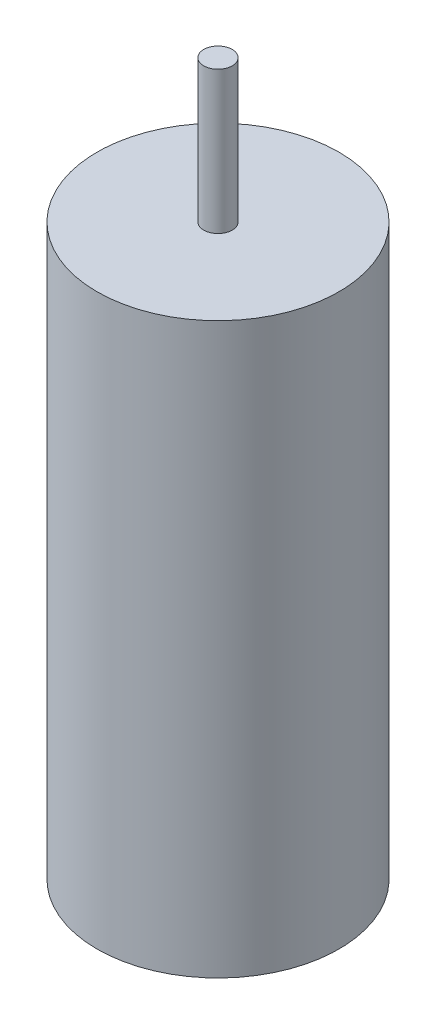
from build123d import *

# Parameters (mm, degrees)
SKETCH_1_R      = 4.25
EXTRUDE_1_DEPTH = 20
SKETCH_2_R      = 0.5
EXTRUDE_2_DEPTH = 5


with BuildPart() as part:
    # 草图1 → 凸台-拉伸1 (new body)
    with BuildSketch(Plane(origin=(0, 0, 0), x_dir=(1, 0, 0), z_dir=(0, 1, 0))):
        Circle(SKETCH_1_R)
    extrude(amount=EXTRUDE_1_DEPTH)

    # 草图2 → 凸台-拉伸2 (add)
    with BuildSketch(Plane(origin=(0, 20, 0), x_dir=(1, 0, 0), z_dir=(0, 1, 0))):
        Circle(SKETCH_2_R)
    extrude(amount=EXTRUDE_2_DEPTH)


solid = part.part
